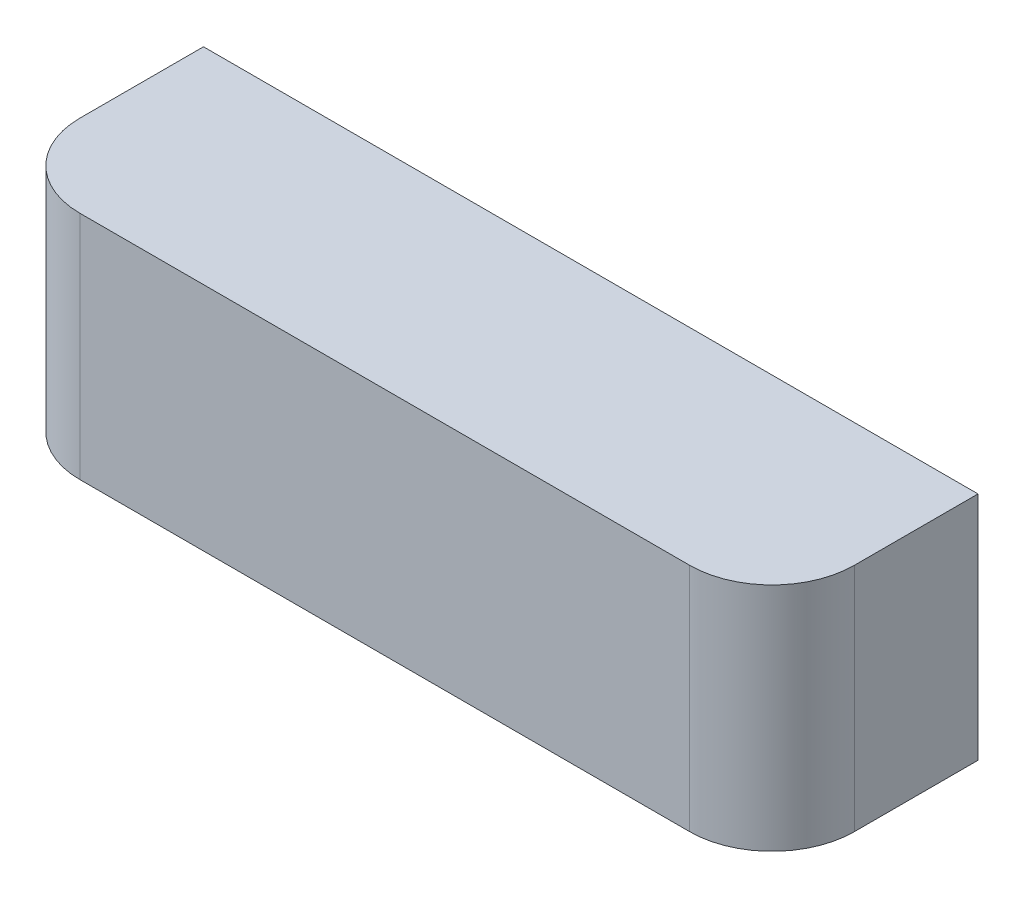
from build123d import *

# Parameters (mm, degrees)
SKETCH1_W           = 94
SKETCH1_H           = 28
BOSS_EXTRUDE1_DEPTH = 25
FILLET1_R           = 10
SKETCH2_W           = 13
SKETCH2_H           = 9.5
BOSS_EXTRUDE2_DEPTH = 10


with BuildPart() as part:
    # Sketch1 → Boss-Extrude1 (new body)
    with BuildSketch(Plane.XY):
        Rectangle(SKETCH1_W, SKETCH1_H)
    extrude(amount=BOSS_EXTRUDE1_DEPTH)

    # Fillet1
    fillet1_edges = [part.edges().sort_by_distance(p)[0] for p in [
        (-47, 0, 25),
        (47, 0, 25),
    ]]
    fillet(fillet1_edges, radius=FILLET1_R)

    # Sketch2 → Boss-Extrude2 (add)
    with BuildSketch(Plane(origin=(0, 0, 0), x_dir=(-1, 0, 0), z_dir=(0, 0, -1))):
        with Locations((-13.5, -3.75)):
            Rectangle(SKETCH2_W, SKETCH2_H)
    extrude(amount=BOSS_EXTRUDE2_DEPTH)


solid = part.part
